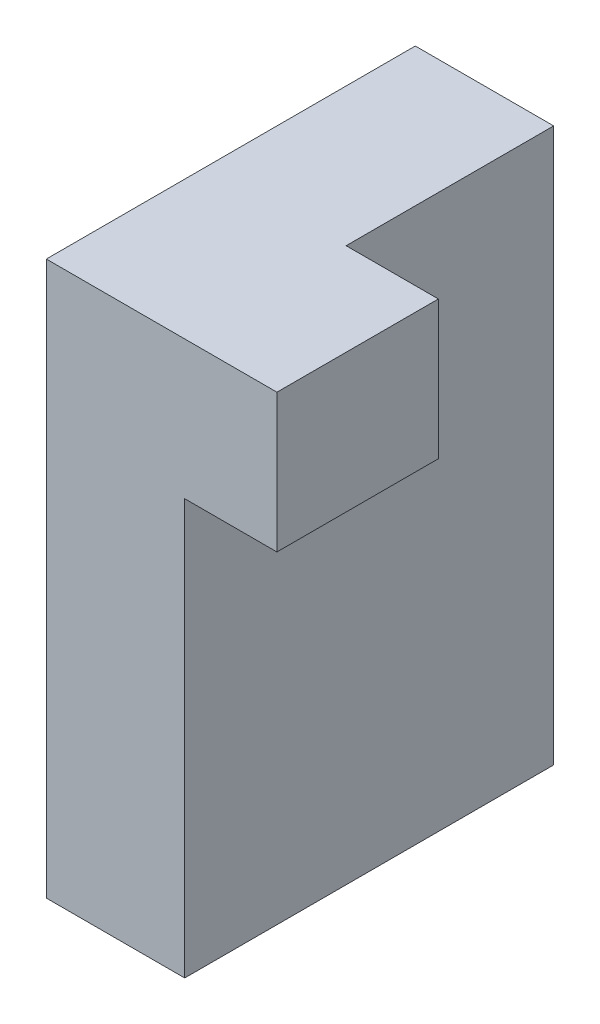
from build123d import *

# Parameters (mm, degrees)
SKETCH1_W           = 50.8
SKETCH1_H           = 76.2
BOSS_EXTRUDE1_DEPTH = 9.525
SKETCH3_W           = 22.225
SKETCH3_H           = 19.05
BOSS_EXTRUDE3_DEPTH = 12.7


with BuildPart() as part:
    # Sketch1 → Boss-Extrude1 (new body, symmetric)
    with BuildSketch(Plane(origin=(0, 0, 0), x_dir=(0, 0, -1), z_dir=(1, 0, 0))):
        Rectangle(SKETCH1_W, SKETCH1_H)
    extrude(amount=BOSS_EXTRUDE1_DEPTH, both=True)

    # Sketch3 → Boss-Extrude3 (add)
    with BuildSketch(Plane(origin=(9.525, 0, 0), x_dir=(0, 0, -1), z_dir=(1, 0, 0))):
        with Locations((-14.2875, 28.575)):
            Rectangle(SKETCH3_W, SKETCH3_H)
    extrude(amount=BOSS_EXTRUDE3_DEPTH)


solid = part.part
